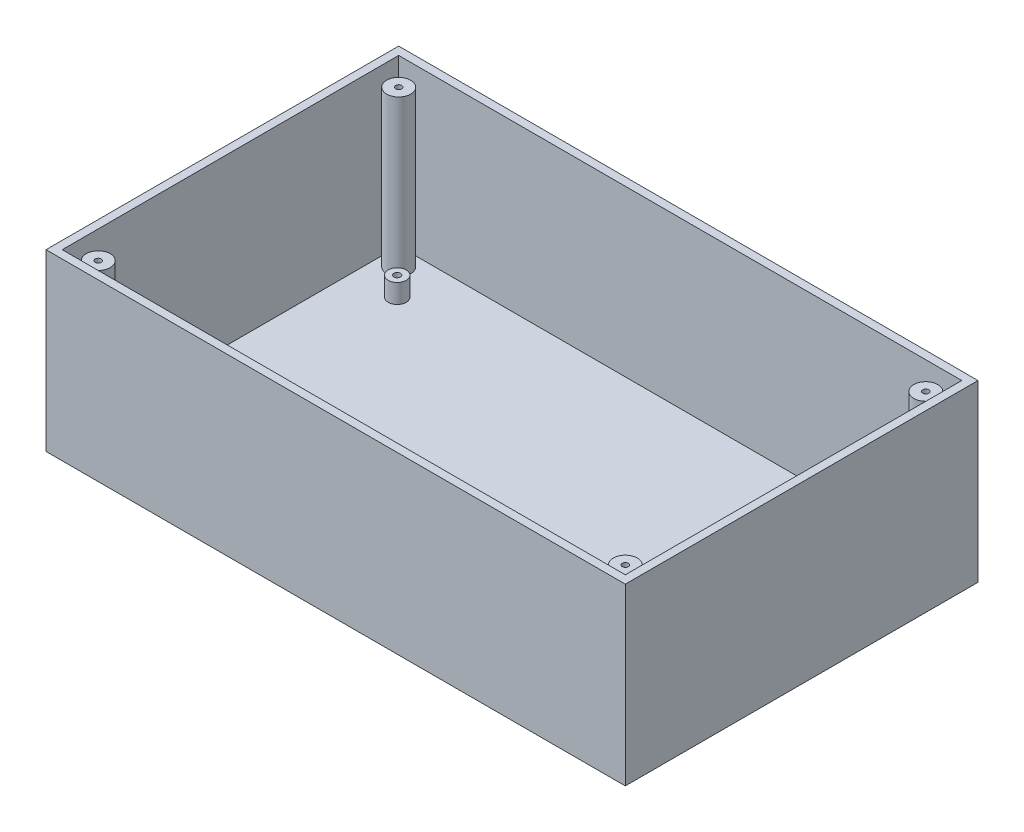
from build123d import *

# Parameters (mm, degrees)
SKETCH1_W               = 193
SKETCH1_H               = 117.5
BOSS_EXTRUDE1_DEPTH     = 3.22
SKETCH3_W               = 193
SKETCH3_H               = 117.5
SKETCH3_W_2             = 187.6
SKETCH3_H_2             = 112.1
BOSS_EXTRUDE2_DEPTH     = 55
SKETCH4_R               = 3
SKETCH4_R_2             = 1.1
BOSS_EXTRUDE3_DEPTH     = 6.36
SKETCH6_R               = 4
SKETCH6_R_2             = 1
BOSS_EXTRUDE4_DEPTH     = 51.84
SKETCH7_R               = 4.7625
CUT_EXTRUDE1_DEPTH      = 56
CUT_EXTRUDE1_DEPTH_BACK = 4.22
F_1_4_CLEARANCE_HOLE1_D = 6.7564


with BuildPart() as part:
    # Sketch1 → Boss-Extrude1 (new body)
    with BuildSketch(Plane(origin=(0, 0, 0), x_dir=(1, 0, 0), z_dir=(0, 1, 0))):
        with Locations((96.5, 58.75)):
            Rectangle(SKETCH1_W, SKETCH1_H)
    extrude(amount=BOSS_EXTRUDE1_DEPTH)

    # Sketch3 → Boss-Extrude2 (add)
    with BuildSketch(Plane(origin=(0, 3.22, 0), x_dir=(1, 0, 0), z_dir=(0, 1, 0))):
        with Locations((96.5, 58.75)):
            Rectangle(SKETCH3_W, SKETCH3_H)
        with Locations((96.5, 58.75)):
            Rectangle(SKETCH3_W_2, SKETCH3_H_2, mode=Mode.SUBTRACT)
    extrude(amount=BOSS_EXTRUDE2_DEPTH)

    # Sketch4 → Boss-Extrude3 (add)
    with BuildSketch(Plane(origin=(0, 3.22, 0), x_dir=(1, 0, 0), z_dir=(0, 1, 0))):
        with Locations(Location((17.2, 17.7, 0), (0, 0, 90))):  # turned: the seam where the file's is
            Circle(SKETCH4_R)
        with Locations(Location((17.2, 17.7, 0), (0, 0, 270))):  # turned: the seam where the file's is
            Circle(SKETCH4_R_2, mode=Mode.SUBTRACT)
        with Locations(Location((175.8, 17.7, 0), (0, 0, 90))):  # turned: the seam where the file's is
            Circle(SKETCH4_R)
        with Locations(Location((175.8, 17.7, 0), (0, 0, 90))):  # turned: the seam where the file's is
            Circle(SKETCH4_R_2, mode=Mode.SUBTRACT)
        with Locations(Location((17.2, 99.8, 0), (0, 0, 90))):  # turned: the seam where the file's is
            Circle(SKETCH4_R)
        with Locations(Location((17.2, 99.8, 0), (0, 0, 90))):  # turned: the seam where the file's is
            Circle(SKETCH4_R_2, mode=Mode.SUBTRACT)
        with Locations(Location((175.8, 99.8, 0), (0, 0, 90))):  # turned: the seam where the file's is
            Circle(SKETCH4_R)
        with Locations(Location((175.8, 99.8, 0), (0, 0, 270))):  # turned: the seam where the file's is
            Circle(SKETCH4_R_2, mode=Mode.SUBTRACT)
    extrude(amount=BOSS_EXTRUDE3_DEPTH)

    # Sketch6 → Boss-Extrude4 (add)
    with BuildSketch(Plane(origin=(0, 3.22, 0), x_dir=(1, 0, 0), z_dir=(0, 1, 0))):
        with Locations(Location((8.7, 8.7, 0), (0, 0, 90))):  # turned: the seam where the file's is
            Circle(SKETCH6_R)
        with Locations(Location((8.7, 8.7, 0), (0, 0, 90))):  # turned: the seam where the file's is
            Circle(SKETCH6_R_2, mode=Mode.SUBTRACT)
        with Locations(Location((184.3, 8.7, 0), (0, 0, 90))):  # turned: the seam where the file's is
            Circle(SKETCH6_R)
        with Locations(Location((184.3, 8.7, 0), (0, 0, 90))):  # turned: the seam where the file's is
            Circle(SKETCH6_R_2, mode=Mode.SUBTRACT)
        with Locations(Location((184.3, 108.8, 0), (0, 0, 90))):  # turned: the seam where the file's is
            Circle(SKETCH6_R)
        with Locations(Location((184.3, 108.8, 0), (0, 0, 90))):  # turned: the seam where the file's is
            Circle(SKETCH6_R_2, mode=Mode.SUBTRACT)
        with Locations(Location((8.7, 108.8, 0), (0, 0, 90))):  # turned: the seam where the file's is
            Circle(SKETCH6_R)
        with Locations(Location((8.7, 108.8, 0), (0, 0, 90))):  # turned: the seam where the file's is
            Circle(SKETCH6_R_2, mode=Mode.SUBTRACT)
    extrude(amount=BOSS_EXTRUDE4_DEPTH)

    # Sketch7 → Cut-Extrude1 (cut, two sides)
    with BuildSketch(Plane(origin=(0, 3.22, 0), x_dir=(1, 0, 0), z_dir=(0, 1, 0))) as cut_extrude1_sk:
        with Locations(Location((45, 45, 0), (0, 0, 270))):  # turned: the seam where the file's is
            Circle(SKETCH7_R)
    extrude(amount=CUT_EXTRUDE1_DEPTH, mode=Mode.SUBTRACT)
    extrude(cut_extrude1_sk.sketch, amount=-CUT_EXTRUDE1_DEPTH_BACK, mode=Mode.SUBTRACT)

    # 1/4 Clearance Hole1 (through all)
    with Locations(Plane(origin=(0, 3.22, 0), x_dir=(1, 0, 0), z_dir=(0, 1, 0))):
        with Locations((58.01, 45), (31.99, 45)):
            Hole(F_1_4_CLEARANCE_HOLE1_D / 2)


solid = part.part
